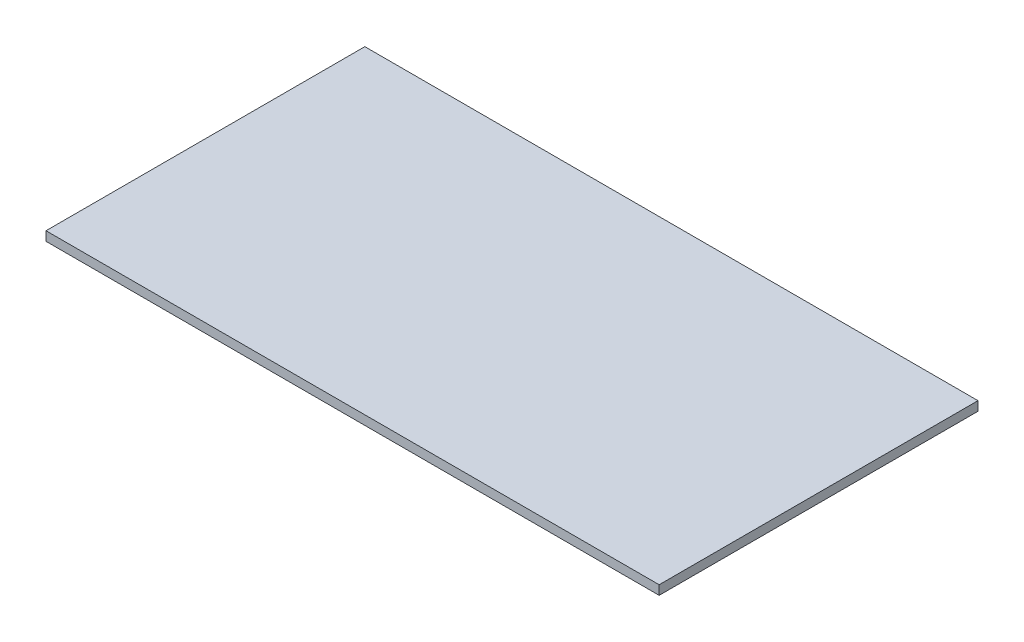
from build123d import *

# Parameters (mm, degrees)
SKETCH1_W           = 1270
SKETCH1_H           = 660.4
BOSS_EXTRUDE1_DEPTH = 19.05


with BuildPart() as part:
    # Sketch1 → Boss-Extrude1 (new body)
    with BuildSketch(Plane(origin=(0, 0, 0), x_dir=(1, 0, 0), z_dir=(0, 1, 0))):
        Rectangle(SKETCH1_W, SKETCH1_H)
    extrude(amount=BOSS_EXTRUDE1_DEPTH)


solid = part.part
